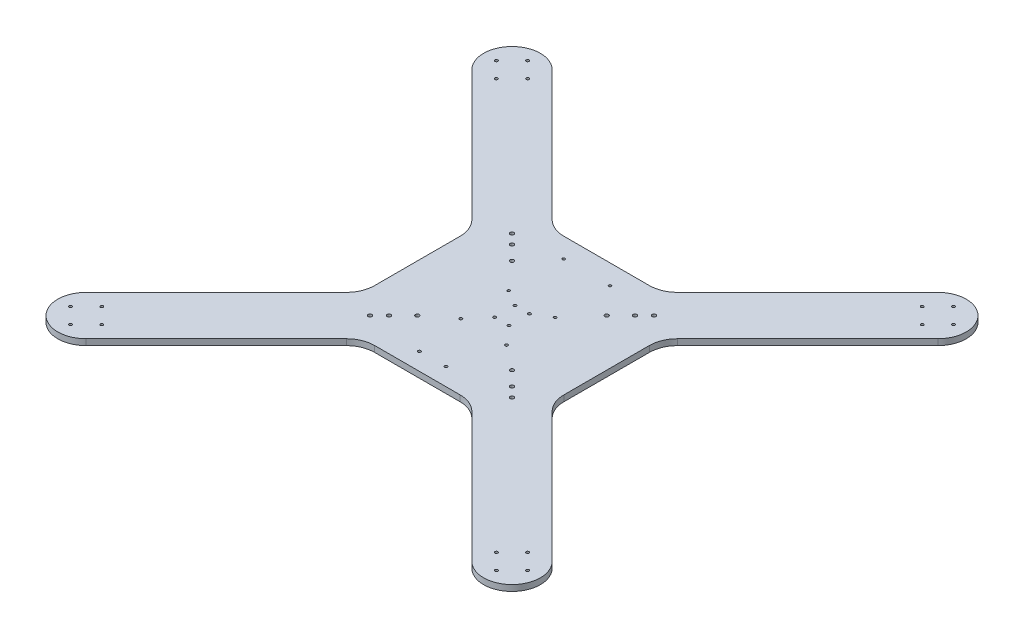
from build123d import *

# Parameters (mm, degrees)
BOSS_EXTRUDE1_DEPTH = 6.35
SKETCH2_R           = 1.5
CUT_EXTRUDE1_DEPTH  = 212
SKETCH3_R           = 1.5
CUT_EXTRUDE2_DEPTH  = 212
SKETCH4_R           = 1.375
CUT_EXTRUDE3_DEPTH  = 212
SKETCH5_R           = 1.5
CUT_EXTRUDE4_DEPTH  = 212
SKETCH6_R           = 2
CUT_EXTRUDE5_DEPTH  = 212


with BuildPart() as part:
    # Sketch1 → Boss-Extrude1 (new body)
    with BuildSketch(Plane(origin=(0, 0, 0), x_dir=(1, 0, 0), z_dir=(0, 1, 0))):
        with BuildLine():
            Line((-246.189194392, 203.762814663), (-108.786796564, 66.360416836))
            ThreePointArc((-108.786796564, 66.360416836), (-102.283614025, 56.627716371), (-100, 45.1472134))
            Line((-100, 45.1472134), (-100, -45.1472134))
            ThreePointArc((-100, -45.1472134), (-102.283614025, -56.627716371), (-108.786796564, -66.360416836))
            Line((-108.786796564, -66.360416836), (-246.189194392, -203.762814663))
            ThreePointArc((-246.189194392, -203.762814663), (-246.225197781, -246.201202305), (-203.786796564, -246.213203436))
            Line((-203.786796564, -246.213203436), (-66.360389693, -108.786796564))
            ThreePointArc((-66.360389693, -108.786796564), (-56.627689229, -102.283614025), (-45.147186258, -100))
            Line((-45.147186258, -100), (45.147186258, -100))
            ThreePointArc((45.147186258, -100), (56.627689229, -102.283614025), (66.360389693, -108.786796564))
            Line((66.360389693, -108.786796564), (203.786796564, -246.213203436))
            ThreePointArc((203.786796564, -246.213203436), (246.225197781, -246.201202305), (246.189194392, -203.762814663))
            Line((246.189194392, -203.762814663), (108.786796564, -66.360416836))
            ThreePointArc((108.786796564, -66.360416836), (102.283614025, -56.627716371), (100, -45.1472134))
            Line((100, -45.1472134), (100, 45.1472134))
            ThreePointArc((100, 45.1472134), (102.283614025, 56.627716371), (108.786796564, 66.360416836))
            Line((108.786796564, 66.360416836), (246.189194392, 203.762814663))
            ThreePointArc((246.189194392, 203.762814663), (246.225197781, 246.201202305), (203.786796564, 246.213203436))
            Line((203.786796564, 246.213203436), (66.360389693, 108.786796564))
            ThreePointArc((66.360389693, 108.786796564), (56.627689229, 102.283614025), (45.147186258, 100))
            Line((45.147186258, 100), (-45.147186258, 100))
            ThreePointArc((-45.147186258, 100), (-56.627689229, 102.283614025), (-66.360389693, 108.786796564))
            Line((-66.360389693, 108.786796564), (-203.786796564, 246.213203436))
            ThreePointArc((-203.786796564, 246.213203436), (-246.225197781, 246.201202305), (-246.189194392, 203.762814663))
        make_face()
    extrude(amount=BOSS_EXTRUDE1_DEPTH)

    # Sketch2 → Cut-Extrude1 (cut)
    with BuildSketch(Plane(origin=(0, 6.35, 0), x_dir=(1, 0, 0), z_dir=(0, 1, 0))):
        with Locations((-225, 241.5)):
            Circle(SKETCH2_R)
        with Locations((-208.5, 225)):
            Circle(SKETCH2_R)
        with Locations((-225, 208.5)):
            Circle(SKETCH2_R)
        with Locations((-241.5, 225)):
            Circle(SKETCH2_R)
        with Locations((241.5, 225)):
            Circle(SKETCH2_R)
        with Locations((225, 241.5)):
            Circle(SKETCH2_R)
        with Locations((208.5, 225)):
            Circle(SKETCH2_R)
        with Locations((225, 208.5)):
            Circle(SKETCH2_R)
        with Locations((225, -241.5)):
            Circle(SKETCH2_R)
        with Locations((241.5, -225)):
            Circle(SKETCH2_R)
        with Locations((225, -208.5)):
            Circle(SKETCH2_R)
        with Locations((208.5, -225)):
            Circle(SKETCH2_R)
        with Locations((-241.5, -225)):
            Circle(SKETCH2_R)
        with Locations((-225, -241.5)):
            Circle(SKETCH2_R)
        with Locations((-208.5, -225)):
            Circle(SKETCH2_R)
        with Locations((-225, -208.5)):
            Circle(SKETCH2_R)
    extrude(amount=-CUT_EXTRUDE1_DEPTH, mode=Mode.SUBTRACT)

    # Sketch3 → Cut-Extrude2 (cut)
    with BuildSketch(Plane(origin=(0, 6.35, 0), x_dir=(1, 0, 0), z_dir=(0, 1, 0))):
        with Locations((-7.62, 10.795)):
            Circle(SKETCH3_R)
        with Locations((-7.62, -10.795)):
            Circle(SKETCH3_R)
        with Locations((7.62, -10.795)):
            Circle(SKETCH3_R)
        with Locations((7.62, 10.795)):
            Circle(SKETCH3_R)
    extrude(amount=-CUT_EXTRUDE2_DEPTH, mode=Mode.SUBTRACT)

    # Sketch4 → Cut-Extrude3 (cut)
    with BuildSketch(Plane(origin=(0, 6.35, 0), x_dir=(1, 0, 0), z_dir=(0, 1, 0))):
        with Locations((-24.5, 21)):
            Circle(SKETCH4_R)
        with Locations((24.5, 21)):
            Circle(SKETCH4_R)
        with Locations((24.5, 79)):
            Circle(SKETCH4_R)
        with Locations((-24.5, 79)):
            Circle(SKETCH4_R)
    extrude(amount=-CUT_EXTRUDE3_DEPTH, mode=Mode.SUBTRACT)

    # Sketch5 → Cut-Extrude4 (cut)
    with BuildSketch(Plane(origin=(0, 6.35, 0), x_dir=(1, 0, 0), z_dir=(0, 1, 0))):
        with Locations((24.15, -30)):
            Circle(SKETCH5_R)
        with Locations((-24.15, -30)):
            Circle(SKETCH5_R)
        with Locations((-16.141801743, -81.683254161)):
            Circle(SKETCH5_R)
        with Locations((11.857903914, -81.554867605)):
            Circle(SKETCH5_R)
    extrude(amount=-CUT_EXTRUDE4_DEPTH, mode=Mode.SUBTRACT)

    # Sketch6 → Cut-Extrude5 (cut)
    with BuildSketch(Plane(origin=(0, 6.35, 0), x_dir=(1, 0, 0), z_dir=(0, 1, 0))):
        with Locations((75, 75)):
            Circle(SKETCH6_R)
        with Locations((65, 65)):
            Circle(SKETCH6_R)
        with Locations((50, 50)):
            Circle(SKETCH6_R)
        with Locations((50, -50)):
            Circle(SKETCH6_R)
        with Locations((65, -65)):
            Circle(SKETCH6_R)
        with Locations((75, -75)):
            Circle(SKETCH6_R)
        with Locations((-50, -50)):
            Circle(SKETCH6_R)
        with Locations((-65, -65)):
            Circle(SKETCH6_R)
        with Locations((-75, -75)):
            Circle(SKETCH6_R)
        with Locations((-50, 50)):
            Circle(SKETCH6_R)
        with Locations((-65, 65)):
            Circle(SKETCH6_R)
        with Locations((-75, 75)):
            Circle(SKETCH6_R)
    extrude(amount=-CUT_EXTRUDE5_DEPTH, mode=Mode.SUBTRACT)


solid = part.part
